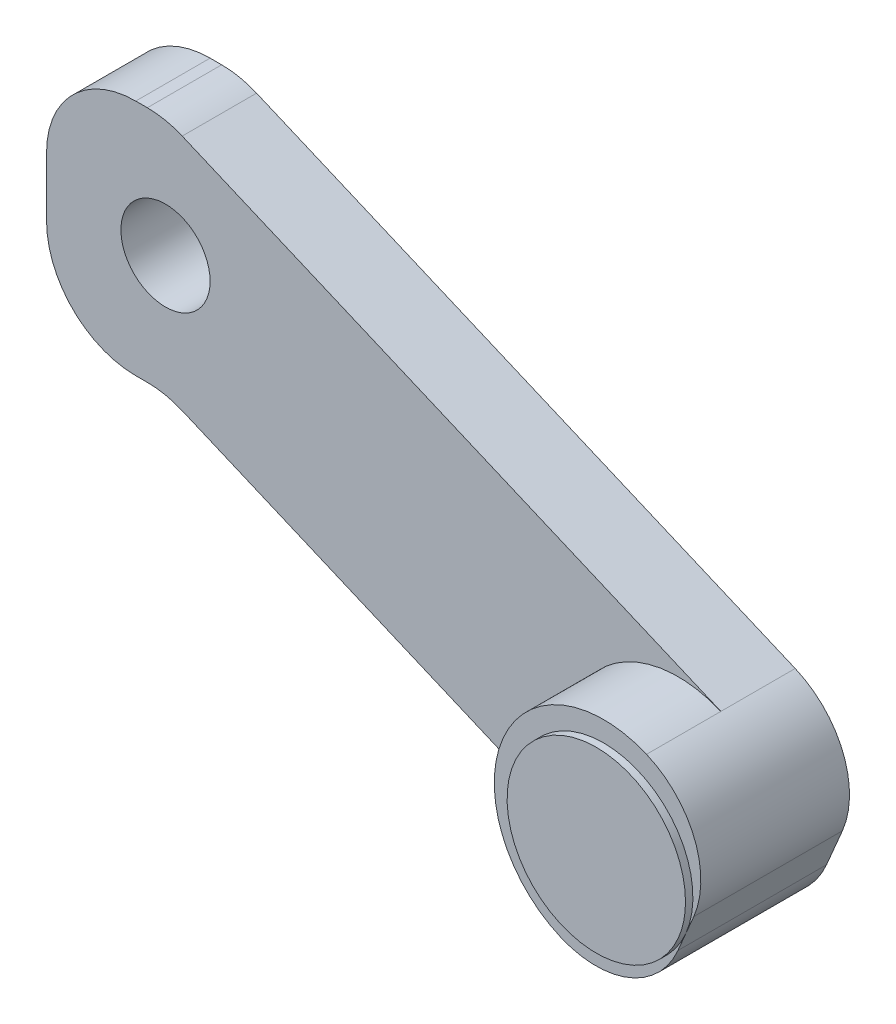
from build123d import *

# Parameters (mm, degrees)
ESBO_O1_R                = 3
RESSALTO_EXTRUS_O1_DEPTH = 5
FILETE1_R                = 6
RESSALTO_EXTRUS_O2_DEPTH = 5
ESBO_O3_R                = 6
RESSALTO_EXTRUS_O3_DEPTH = 0.5


with BuildPart() as part:
    # Esboço1 → Ressalto-extrusão1 (new body)
    with BuildSketch(Plane.XY):
        Polygon((-8, -8), (-8, 8), (0, 8), (42.879830598, -10.223928004), (37.120169402, -23.776071996), (0, -8), align=None)
        Circle(ESBO_O1_R, mode=Mode.SUBTRACT)
    extrude(amount=RESSALTO_EXTRUS_O1_DEPTH)

    # Filete1
    filete1_edges = [part.edges().sort_by_distance(p)[0] for p in [
        (-8, -8, 2.5),
        (0, -8, 2.5),
        (37.120169402, -23.776071996, 2.5),
        (42.879830598, -10.223928004, 2.5),
        (0, 8, 2.5),
        (-8, 8, 2.5),
    ]]
    fillet(filete1_edges, radius=FILETE1_R)

    # Esboço2 → Ressalto-extrusão2 (add)
    with BuildSketch(Plane.XY.offset(5)):
        with BuildLine():
            Line((39.467013244, -18.254086485), (40.532986756, -15.745913515))
            ThreePointArc((40.532986756, -15.745913515), (40.575103841, -11.153905468), (37.357845087, -7.877084162))
            ThreePointArc((37.357845087, -7.877084162), (36.552086472, -7.588681558), (35.718304651, -7.395728495))
            ThreePointArc((35.718304651, -7.395728495), (27.413539889, -12.579084175), (31.598183891, -21.429228154))
            ThreePointArc((31.598183891, -21.429228154), (36.190191938, -21.471345238), (39.467013244, -18.254086485))
        make_face()
    extrude(amount=RESSALTO_EXTRUS_O2_DEPTH)

    # Esboço3 → Ressalto-extrusão3 (add)
    with BuildSketch(Plane.XY.offset(10)):
        with Locations((34.478014489, -14.653156158)):
            Circle(ESBO_O3_R)
    extrude(amount=RESSALTO_EXTRUS_O3_DEPTH)


solid = part.part
